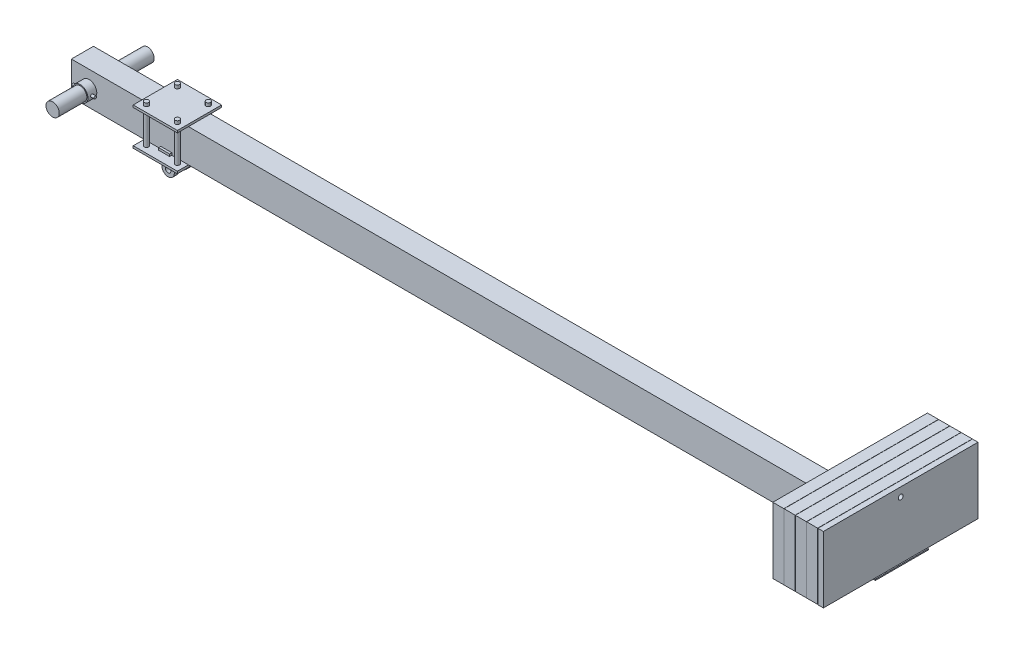
from build123d import *

# Parameters (mm, degrees)
BOSS_EXTRUDE1_DEPTH      = 50
SKETCH2_W                = 3674
SKETCH2_H                = 138
CUT_EXTRUDE1_DEPTH       = 44
SKETCH3_W                = 50
SKETCH3_H                = 300
BOSS_EXTRUDE2_DEPTH      = 350
SKETCH6_W                = 200
SKETCH6_H                = 10
BOSS_EXTRUDE4_DEPTH      = 100
SKETCH14_R               = 35
CUT_EXTRUDE5_DEPTH       = 96
SKETCH15_R               = 35
SKETCH15_R_2             = 30
BOSS_EXTRUDE9_DEPTH      = 90
SKETCH8_R                = 30
BOSS_EXTRUDE6_DEPTH      = 215
SKETCH9_R                = 12.5
BOSS_EXTRUDE7_DEPTH      = 42
SKETCH10_W               = 40
SKETCH10_H               = 91
CUT_EXTRUDE3_DEPTH       = 84
CUT_EXTRUDE3_DEPTH_BACK  = 170
SKETCH11_R               = 10
BOSS_EXTRUDE8_DEPTH      = 100
BOSS_EXTRUDE8_DEPTH_BACK = 100
SKETCH24_W               = 50
SKETCH24_H               = 10
BOSS_EXTRUDE15_DEPTH     = 10
SKETCH25_W               = 50
SKETCH25_H               = 10
BOSS_EXTRUDE16_DEPTH     = 10
SKETCH16_W               = 380
SKETCH16_H               = 240
BOSS_EXTRUDE10_DEPTH     = 5
BOSS_EXTRUDE11_START     = 1
BOSS_EXTRUDE11_DEPTH     = 50
BOSS_EXTRUDE12_START     = 1
BOSS_EXTRUDE12_DEPTH     = 50
BOSS_EXTRUDE13_START     = 1
BOSS_EXTRUDE13_DEPTH     = 50
BOSS_EXTRUDE14_START     = 1
BOSS_EXTRUDE14_DEPTH     = 50
CUT_EXTRUDE6_DEPTH       = 5
SKETCH22_R               = 8
CUT_EXTRUDE7_DEPTH       = 30
SKETCH23_R               = 11
CUT_EXTRUDE8_DEPTH       = 254
SKETCH28_R               = 6
BOSS_EXTRUDE17_DEPTH     = 50
SKETCH29_W               = 700
SKETCH29_H               = 300
CUT_EXTRUDE10_DEPTH      = 25


with BuildPart() as part:
    # Sketch1 → Boss-Extrude1 (new body, symmetric)
    with BuildSketch(Plane.XY):
        Polygon((0, -75), (3600, -75), (3650, -75), (3650, 225), (3600, 225), (3600, 75), (0, 75), (-80, 75), (-80, -75), align=None)
    extrude(amount=BOSS_EXTRUDE1_DEPTH, both=True)

    # Sketch2 → Cut-Extrude1 (cut, symmetric)
    with BuildSketch(Plane.XY):
        with Locations((1763, 0)):
            Rectangle(SKETCH2_W, SKETCH2_H)
    extrude(amount=CUT_EXTRUDE1_DEPTH, both=True, mode=Mode.SUBTRACT)

    # Sketch3 → Boss-Extrude2 (add, symmetric)
    with BuildSketch(Plane.XY):
        with Locations((3625, 75)):
            Rectangle(SKETCH3_W, SKETCH3_H)
    extrude(amount=BOSS_EXTRUDE2_DEPTH, both=True)

    # Sketch6 → Boss-Extrude4 (add, symmetric)
    with BuildSketch(Plane.XY):
        with Locations((350, 80)):
            Rectangle(SKETCH6_W, SKETCH6_H)
        with Locations((350, -80)):
            Rectangle(SKETCH6_W, SKETCH6_H)
    extrude(amount=BOSS_EXTRUDE4_DEPTH, both=True)

    # Sketch14 → Cut-Extrude5 (cut, symmetric)
    with BuildSketch(Plane.XY):
        Circle(SKETCH14_R)
    extrude(amount=CUT_EXTRUDE5_DEPTH, both=True, mode=Mode.SUBTRACT)

    # Sketch15 → Boss-Extrude9 (add, symmetric)
    with BuildSketch(Plane.XY):
        Circle(SKETCH15_R)
        Circle(SKETCH15_R_2, mode=Mode.SUBTRACT)
    extrude(amount=BOSS_EXTRUDE9_DEPTH, both=True)

    # Sketch8 → Boss-Extrude6 (add, symmetric)
    with BuildSketch(Plane.XY):
        Circle(SKETCH8_R)
    extrude(amount=BOSS_EXTRUDE6_DEPTH, both=True)

    # Sketch9 → Boss-Extrude7 (add, symmetric)
    with BuildSketch(Plane.XY):
        with BuildLine():
            Line((295, -85), (295, -110))
            Line((295, -110), (322, -110))
            Line((322, -110), (322, -148))
            ThreePointArc((322, -148), (350, -176), (378, -148))
            Line((378, -148), (378, -110))
            Line((378, -110), (405, -110))
            Line((405, -110), (405, -85))
            Line((405, -85), (295, -85))
        make_face()
        with Locations((350, -148)):
            Circle(SKETCH9_R, mode=Mode.SUBTRACT)
    extrude(amount=BOSS_EXTRUDE7_DEPTH, both=True)

    # Sketch10 → Cut-Extrude3 (cut, two sides)
    with BuildSketch(Plane.ZY.offset(-322)) as cut_extrude3_sk:
        with Locations((0, -130.5)):
            Rectangle(SKETCH10_W, SKETCH10_H)
    extrude(amount=CUT_EXTRUDE3_DEPTH, mode=Mode.SUBTRACT)
    extrude(cut_extrude3_sk.sketch, amount=-CUT_EXTRUDE3_DEPTH_BACK, mode=Mode.SUBTRACT)

    # Sketch11 → Boss-Extrude8 (add, two sides)
    with BuildSketch(Plane(origin=(0, 0, 0), x_dir=(1, 0, 0), z_dir=(0, 1, 0))) as boss_extrude8_sk:
        with Locations((420, 70)):
            Circle(SKETCH11_R)
        with Locations((420, -70)):
            Circle(SKETCH11_R)
        with Locations((280, -70)):
            Circle(SKETCH11_R)
        with Locations((280, 70)):
            Circle(SKETCH11_R)
    extrude(amount=BOSS_EXTRUDE8_DEPTH)
    extrude(boss_extrude8_sk.sketch, amount=-BOSS_EXTRUDE8_DEPTH_BACK)

    # Sketch24 → Boss-Extrude15 (add)
    with BuildSketch(Plane(origin=(0, 75, 0), x_dir=(1, 0, 0), z_dir=(0, 1, 0))):
        with Locations((350, -55)):
            Rectangle(SKETCH24_W, SKETCH24_H)
        with Locations((350, 55)):
            Rectangle(SKETCH24_W, SKETCH24_H)
    extrude(amount=-BOSS_EXTRUDE15_DEPTH)

    # Sketch25 → Boss-Extrude16 (add)
    with BuildSketch(Plane(origin=(0, -75, 0), x_dir=(1, 0, 0), z_dir=(0, 1, 0))):
        with Locations((350, -55)):
            Rectangle(SKETCH25_W, SKETCH25_H)
        with Locations((350, 55)):
            Rectangle(SKETCH25_W, SKETCH25_H)
    extrude(amount=BOSS_EXTRUDE16_DEPTH)

    # Sketch16 → Boss-Extrude10 (add)
    with BuildSketch(Plane.XZ.offset(75)):
        with Locations((3440, 0)):
            Rectangle(SKETCH16_W, SKETCH16_H)
    extrude(amount=BOSS_EXTRUDE10_DEPTH)

    # Sketch21 → Cut-Extrude6 (cut)
    with BuildSketch(Plane.XZ.offset(80)):
        with BuildLine():
            Line((3290, 89), (3590, 89))
            ThreePointArc((3590, 89), (3599, 80), (3590, 71))
            Line((3590, 71), (3290, 71))
            ThreePointArc((3290, 71), (3281, 80), (3290, 89))
        make_face()
        with BuildLine():
            Line((3290, -89), (3590, -89))
            ThreePointArc((3590, -89), (3599, -80), (3590, -71))
            Line((3590, -71), (3290, -71))
            ThreePointArc((3290, -71), (3281, -80), (3290, -89))
        make_face()
    extrude(amount=-CUT_EXTRUDE6_DEPTH, mode=Mode.SUBTRACT)


with BuildPart() as body_2:
    # Sketch17 → Boss-Extrude11 (new body)
    with BuildSketch(Plane.ZY.offset(-3600).offset(BOSS_EXTRUDE11_START)):
        Polygon((350, 225), (-350, 225), (-350, -74), (-65, -74), (-55, -64), (-55, 75.1), (55, 75.1), (55, -64), (65, -74), (350, -74), align=None)
    extrude(amount=BOSS_EXTRUDE11_DEPTH)


with BuildPart() as body_3:
    # Sketch18 → Boss-Extrude12 (new body)
    with BuildSketch(Plane.ZY.offset(-3549).offset(BOSS_EXTRUDE12_START)):
        Polygon((350, 225), (-350, 225), (-350, -74), (-65, -74), (-55, -64), (-55, 75.1), (55, 75.1), (55, -64), (65, -74), (350, -74), align=None)
    extrude(amount=BOSS_EXTRUDE12_DEPTH)


with BuildPart() as body_4:
    # Sketch19 → Boss-Extrude13 (new body)
    with BuildSketch(Plane.ZY.offset(-3498).offset(BOSS_EXTRUDE13_START)):
        Polygon((350, 225), (-350, 225), (-350, -74), (-65, -74), (-55, -64), (-55, 75.1), (55, 75.1), (55, -64), (65, -74), (350, -74), align=None)
    extrude(amount=BOSS_EXTRUDE13_DEPTH)


with BuildPart() as body_5:
    # Sketch20 → Boss-Extrude14 (new body)
    with BuildSketch(Plane.ZY.offset(-3447).offset(BOSS_EXTRUDE14_START)):
        Polygon((350, 225), (-350, 225), (-350, -74), (-65, -74), (-55, -64), (-55, 75.1), (55, 75.1), (55, -64), (65, -74), (350, -74), align=None)
    extrude(amount=BOSS_EXTRUDE14_DEPTH)


with BuildPart() as cut_extrude7_tool:
    # Sketch22 → Cut-Extrude7 (new body)
    with BuildSketch(Plane.XZ.offset(80)):
        with Locations((3421, 80)):
            Circle(SKETCH22_R)
        with Locations((3472, 80)):
            Circle(SKETCH22_R)
        with Locations((3523, 80)):
            Circle(SKETCH22_R)
        with Locations((3574, 80)):
            Circle(SKETCH22_R)
        with Locations((3574, -80)):
            Circle(SKETCH22_R)
        with Locations((3523, -80)):
            Circle(SKETCH22_R)
        with Locations((3472, -80)):
            Circle(SKETCH22_R)
        with Locations((3421, -80)):
            Circle(SKETCH22_R)
    extrude(amount=-CUT_EXTRUDE7_DEPTH)


with BuildPart() as body_2_1:
    add(body_2.part)

    # Cut-Extrude7: cut by cut_extrude7_tool
    add(cut_extrude7_tool.part, mode=Mode.SUBTRACT)


with BuildPart() as body_3_1:
    add(body_3.part)

    # Cut-Extrude7: cut by cut_extrude7_tool
    add(cut_extrude7_tool.part, mode=Mode.SUBTRACT)


with BuildPart() as body_4_1:
    add(body_4.part)

    # Cut-Extrude7: cut by cut_extrude7_tool
    add(cut_extrude7_tool.part, mode=Mode.SUBTRACT)


with BuildPart() as body_5_1:
    add(body_5.part)

    # Cut-Extrude7: cut by cut_extrude7_tool
    add(cut_extrude7_tool.part, mode=Mode.SUBTRACT)


with BuildPart() as cut_extrude8_tool:
    # Sketch23 → Cut-Extrude8 (new body)
    with BuildSketch(Plane(origin=(3650, 0, 0), x_dir=(0, 0, -1), z_dir=(1, 0, 0))):
        with Locations((0, 185)):
            Circle(SKETCH23_R)
    extrude(amount=-CUT_EXTRUDE8_DEPTH)


with BuildPart() as part_1:
    add(part.part)

    # Cut-Extrude8: cut by cut_extrude8_tool
    add(cut_extrude8_tool.part, mode=Mode.SUBTRACT)

    # Sketch28 → Boss-Extrude17 (add, symmetric)
    with BuildSketch(Plane(origin=(0, 0, 0), x_dir=(0, 0, -1), z_dir=(1, 0, 0))):
        with Locations((-72, 0)):
            Circle(SKETCH28_R)
        with Locations((72, 0)):
            Circle(SKETCH28_R)
    extrude(amount=BOSS_EXTRUDE17_DEPTH, both=True)

    # Sketch29 → Cut-Extrude10 (cut)
    with BuildSketch(Plane(origin=(3650, 0, 0), x_dir=(0, 0, -1), z_dir=(1, 0, 0))):
        with Locations((0, 75)):
            Rectangle(SKETCH29_W, SKETCH29_H)
    extrude(amount=-CUT_EXTRUDE10_DEPTH, mode=Mode.SUBTRACT)


with BuildPart() as body_2_2:
    add(body_2_1.part)

    # Cut-Extrude8: cut by cut_extrude8_tool
    add(cut_extrude8_tool.part, mode=Mode.SUBTRACT)


with BuildPart() as body_3_2:
    add(body_3_1.part)

    # Cut-Extrude8: cut by cut_extrude8_tool
    add(cut_extrude8_tool.part, mode=Mode.SUBTRACT)


with BuildPart() as body_4_2:
    add(body_4_1.part)

    # Cut-Extrude8: cut by cut_extrude8_tool
    add(cut_extrude8_tool.part, mode=Mode.SUBTRACT)


with BuildPart() as body_5_2:
    add(body_5_1.part)

    # Cut-Extrude8: cut by cut_extrude8_tool
    add(cut_extrude8_tool.part, mode=Mode.SUBTRACT)


solid = Compound([part_1.part, body_2_2.part, body_3_2.part, body_4_2.part, body_5_2.part])
